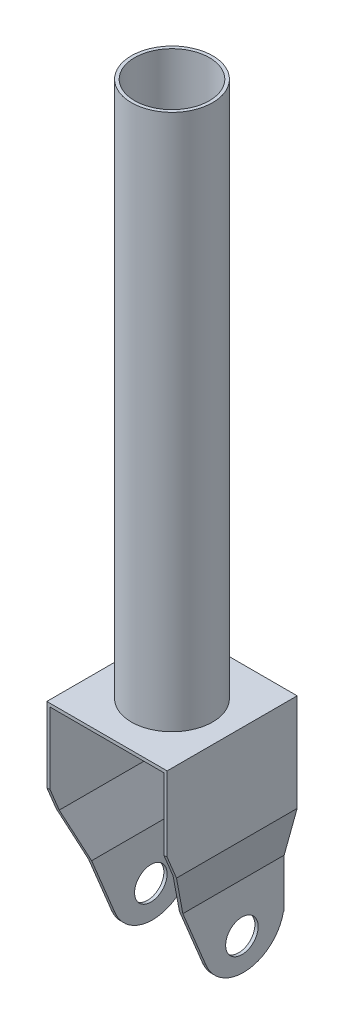
from build123d import *

# Parameters (mm, degrees)
CROQUIS1_R                 = 12.5
SALIENTE_EXTRUIR1_DEPTH    = 165
CROQUIS2_R                 = 11.5
CORTAR_EXTRUIR1_DEPTH      = 166
EXTRUIR_L_MINA1_DEPTH      = 20
CORTAR_EXTRUIR4_DEPTH      = 5
CORTAR_EXTRUIR4_DEPTH_BACK = 34
CROQUIS6_R                 = 2.999725426
CORTAR_EXTRUIR5_DEPTH      = 5


with BuildPart() as part:
    # Croquis1 → Saliente-Extruir1 (new body)
    with BuildSketch(Plane(origin=(0, 0, 0), x_dir=(1, 0, 0), z_dir=(0, 1, 0))):
        Circle(CROQUIS1_R)
    extrude(amount=SALIENTE_EXTRUIR1_DEPTH)

    # Croquis2 → Cortar-Extruir1 (cut, through all)
    with BuildSketch(Plane(origin=(0, 165, 0), x_dir=(1, 0, 0), z_dir=(0, 1, 0))):
        Circle(CROQUIS2_R)
    extrude(amount=-CORTAR_EXTRUIR1_DEPTH, mode=Mode.SUBTRACT)

    # Croquis4 → Extruir-Lámina1 (add)
    with BuildSketch(Plane.XY):
        Polygon((-14.5, -69.456832295), (-14.5, -44.456832295), (-18.5, -30), (-18.5, 0), (18.5, 0), (18.5, -30), (14.5, -44.456832295), (14.5, -69.456832295), (13.5, -69.456832295), (13.5, -44.321040369), (17.5, -29.864208074), (17.5, -1), (-17.5, -1), (-17.5, -29.864208074), (-13.5, -44.321040369), (-13.5, -69.456832295), align=None)
    extruir_l_mina1 = extrude(amount=EXTRUIR_L_MINA1_DEPTH)

    # Simetría1: Extruir-Lámina1 across plane
    add(extruir_l_mina1.mirror(Plane.XY))

    # Croquis5 → Cortar-Extruir4 (cut, two sides)
    with BuildSketch(Plane.ZY.offset(14.5)) as cortar_extruir4_sk:
        Polygon((20, -23), (11.165079241, -44.456832295), (20, -44.456832295), align=None)
        with BuildLine():
            Line((20, -44.456832295), (11.165079241, -44.456832295))
            Line((11.165079241, -44.456832295), (4.058522787, -61.716091794))
            ThreePointArc((4.058522787, -61.716091794), (-0.338082334, -67.201681505), (-7, -69.446828292))
            Line((-7, -69.446828292), (-7, -69.456832295))
            Line((-7, -69.456832295), (20, -69.456832295))
            Line((20, -69.456832295), (20, -44.456832295))
        make_face()
        with BuildLine():
            Line((-19.747448714, -59.456832295), (-20, -59.456832295))
            Line((-20, -59.456832295), (-20, -69.456832295))
            Line((-20, -69.456832295), (-7.500000063, -69.456832295))
            ThreePointArc((-7.500000063, -69.456832295), (-15.405694175, -66.63929064), (-19.747448714, -59.456832295))
        make_face()
        with BuildLine():
            ThreePointArc((-2, -59.456832295), (-7, -54.456832295), (-12, -59.456832295))
            Line((-12, -59.456832295), (-7, -59.456832295))
            Line((-7, -59.456832295), (-7, -64.456832295))
            ThreePointArc((-7, -64.456832295), (-3.464466094, -62.992366201), (-2, -59.456832295))
        make_face()
        with BuildLine():
            Line((-7, -59.456832295), (-12, -59.456832295))
            ThreePointArc((-12, -59.456832295), (-10.535533906, -62.992366201), (-7, -64.456832295))
            Line((-7, -64.456832295), (-7, -59.456832295))
        make_face()
    extrude(amount=CORTAR_EXTRUIR4_DEPTH, mode=Mode.SUBTRACT)
    extrude(cortar_extruir4_sk.sketch, amount=-CORTAR_EXTRUIR4_DEPTH_BACK, mode=Mode.SUBTRACT)

    # Croquis6 → Cortar-Extruir5 (cut, symmetric)
    with BuildSketch(Plane(origin=(-0.184914892, 0, -12.485243343), x_dir=(-0.99989034, 0, 0.014809052), z_dir=(-0.014809052, 0, -0.99989034))):
        with Locations((0.848128323, 108.600309026)):
            Circle(CROQUIS6_R)
    extrude(amount=CORTAR_EXTRUIR5_DEPTH, both=True, mode=Mode.SUBTRACT)


solid = part.part
